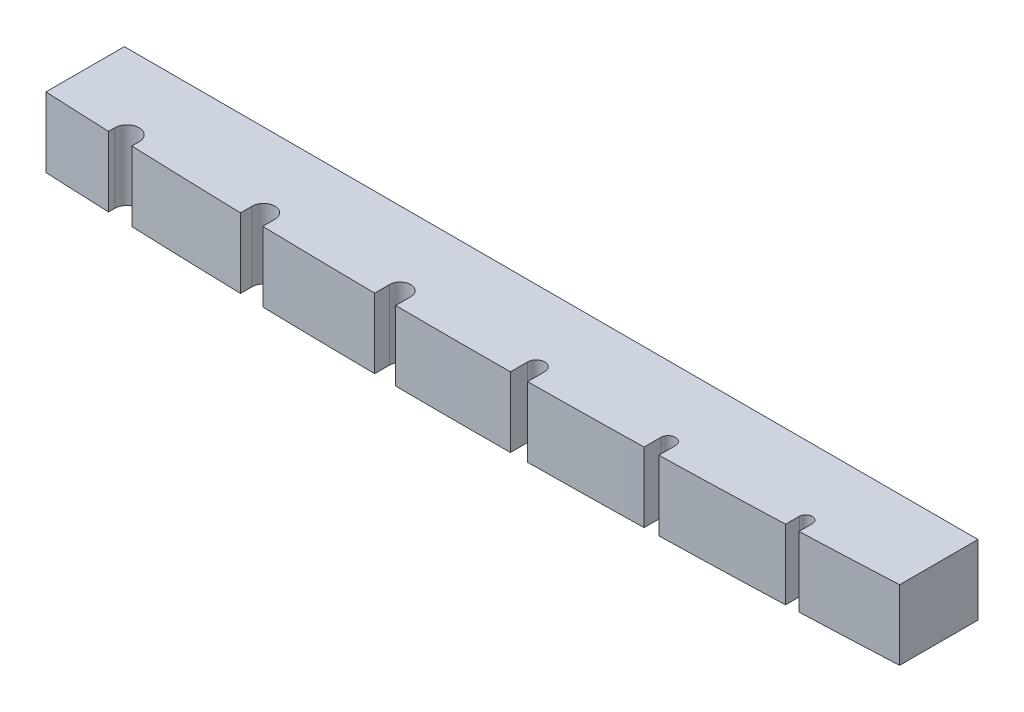
from build123d import *

# Parameters (mm, degrees)
SKETCH1_W           = 41.91
SKETCH1_H           = 4.3561
BOSS_EXTRUDE1_DEPTH = 3.429
CUT_EXTRUDE1_DEPTH  = 3.429
CUT_EXTRUDE2_START  = -3.429
CUT_EXTRUDE2_DEPTH  = 3.429


with BuildPart() as part:
    # Sketch1 → Boss-Extrude1 (new body)
    with BuildSketch(Plane(origin=(0, 0, 0), x_dir=(1, 0, 0), z_dir=(0, 1, 0))):
        with Locations((20.955, 2.17805)):
            Rectangle(SKETCH1_W, SKETCH1_H)
    extrude(amount=BOSS_EXTRUDE1_DEPTH)

    # Sketch3 → Cut-Extrude1 (cut)
    with BuildSketch(Plane(origin=(0, 3.429, 0), x_dir=(1, 0, 0), z_dir=(0, 1, 0))):
        with BuildLine():
            Line((3.2131, 0), (3.2131, 0.673406365))
            ThreePointArc((3.2131, 0.673406365), (3.810306846, 1.27), (4.406900482, 0.672793154))
            Line((4.406900482, 0.672793154), (4.406900482, 0))
            Line((4.406900482, 0), (3.2131, 0))
        make_face()
        with BuildLine():
            Line((9.918700482, 0), (9.918700482, 0.7112))
            ThreePointArc((9.918700482, 0.7112), (10.477500482, 1.27), (11.036300482, 0.7112))
            Line((11.036300482, 0.7112), (11.036300482, 0))
            Line((11.036300482, 0), (9.918700482, 0))
        make_face()
        with BuildLine():
            Line((16.624300482, 0), (16.624300482, 0.7493))
            ThreePointArc((16.624300482, 0.7493), (17.145000482, 1.27), (17.665700482, 0.7493))
            Line((17.665700482, 0.7493), (17.665700482, 0))
            Line((17.665700482, 0), (16.624300482, 0))
        make_face()
        with BuildLine():
            Line((23.304500482, 0), (23.304500482, 0.8509))
            ThreePointArc((23.304500482, 0.8509), (23.723600482, 1.27), (24.142700482, 0.8509))
            Line((24.142700482, 0.8509), (24.142700482, 0))
            Line((24.142700482, 0), (23.304500482, 0))
        make_face()
        with BuildLine():
            Line((29.781500482, 0), (29.781500482, 0.9144))
            ThreePointArc((29.781500482, 0.9144), (30.137100482, 1.27), (30.492700482, 0.9144))
            Line((30.492700482, 0.9144), (30.492700482, 0))
            Line((30.492700482, 0), (29.781500482, 0))
        make_face()
        with BuildLine():
            Line((36.537900482, 0), (36.537900482, 0.9525))
            ThreePointArc((36.537900482, 0.9525), (36.855400482, 1.27), (37.172900482, 0.9525))
            Line((37.172900482, 0.9525), (37.172900482, 0))
            Line((37.172900482, 0), (36.537900482, 0))
        make_face()
    extrude(amount=-CUT_EXTRUDE1_DEPTH, mode=Mode.SUBTRACT)

    # Sketch4 → Cut-Extrude2 (cut)
    with BuildSketch(Plane(origin=(0, 3.429, 0), x_dir=(1, 0, 0), z_dir=(0, 1, 0)).offset(CUT_EXTRUDE2_START)):
        with BuildLine():
            Line((0, 0.508), (0, -0.53864271))
            Line((0, -0.53864271), (41.91, -0.53864271))
            Line((41.91, -0.53864271), (41.91, 0.508))
            ThreePointArc((41.91, 0.508), (20.955, 0), (0, 0.508))
        make_face()
    extrude(amount=CUT_EXTRUDE2_DEPTH, mode=Mode.SUBTRACT)


solid = part.part
